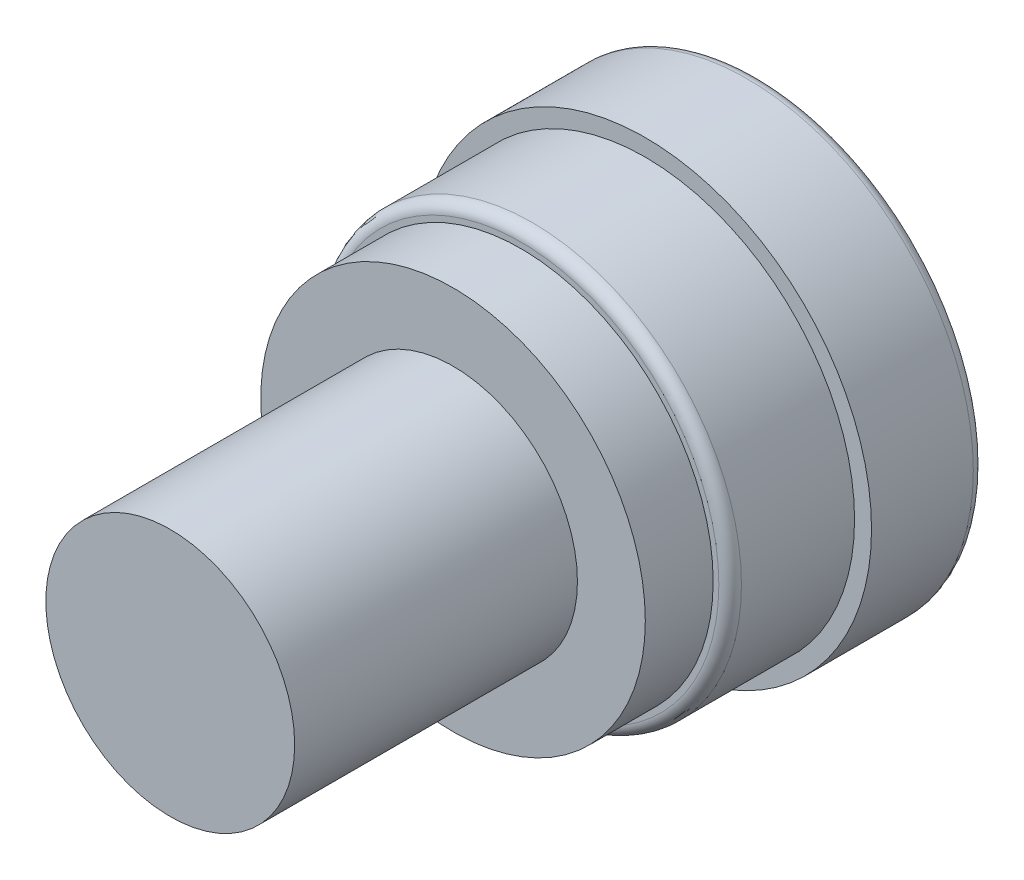
from build123d import *

# Parameters (mm, degrees)
SKETCH1_R           = 20
BOSS_EXTRUDE1_DEPTH = 10
SKETCH2_R           = 18.5
BOSS_EXTRUDE2_DEPTH = 11
SKETCH3_R           = 17
BOSS_EXTRUDE3_DEPTH = 6
SKETCH4_R           = 11
BOSS_EXTRUDE4_DEPTH = 25
FILLET1_R           = 1


with BuildPart() as part:
    # Sketch1 → Boss-Extrude1 (new body)
    with BuildSketch(Plane.XY):
        Circle(SKETCH1_R)
    extrude(amount=BOSS_EXTRUDE1_DEPTH)

    # Sketch2 → Boss-Extrude2 (add)
    with BuildSketch(Plane.XY.offset(10)):
        Circle(SKETCH2_R)
    extrude(amount=BOSS_EXTRUDE2_DEPTH)

    # Sketch3 → Boss-Extrude3 (add)
    with BuildSketch(Plane.XY.offset(21)):
        Circle(SKETCH3_R)
    extrude(amount=BOSS_EXTRUDE3_DEPTH)

    # Sketch4 → Boss-Extrude4 (add)
    with BuildSketch(Plane.XY.offset(27)):
        Circle(SKETCH4_R)
    extrude(amount=BOSS_EXTRUDE4_DEPTH)

    # Fillet1
    fillet1_edges = [part.edges().sort_by_distance(p)[0] for p in [
        (-20, 0, 0),
        (-18.5, 0, 21),
    ]]
    fillet(fillet1_edges, radius=FILLET1_R)


solid = part.part
